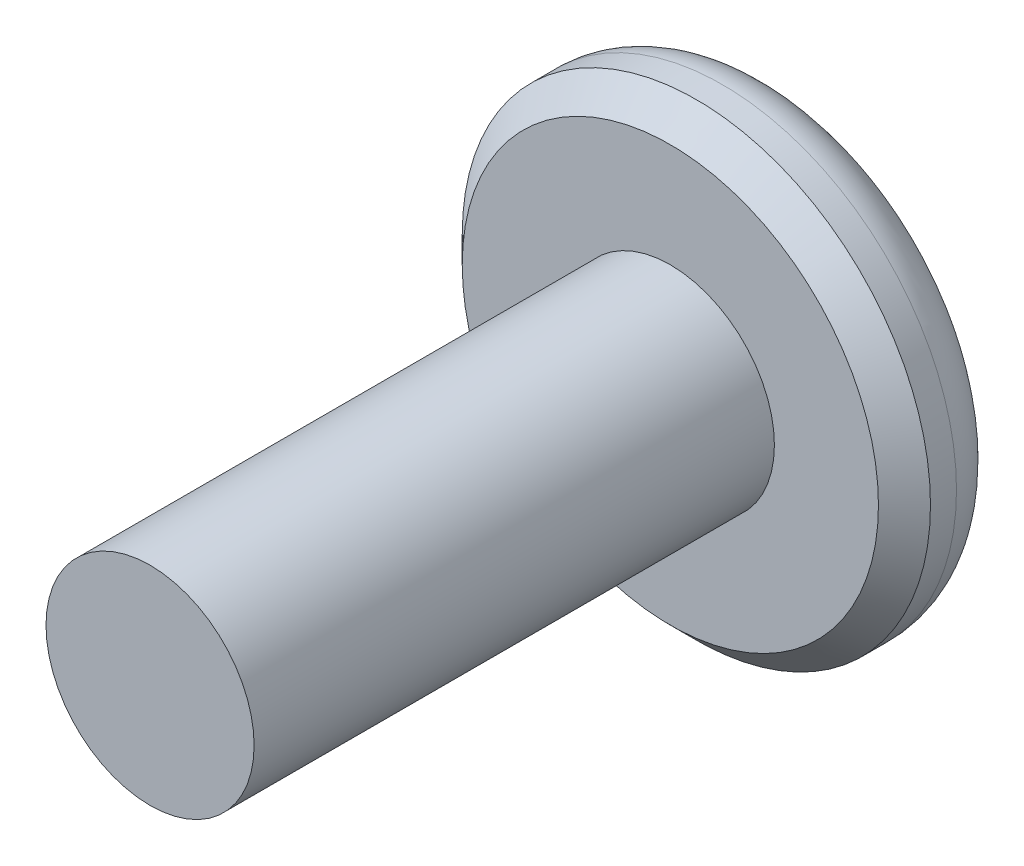
from build123d import *

# Parameters (mm, degrees)
SKETCH_1_R          = 4.5
EXTRUDE_1_DEPTH     = 2
SKETCH_2_R          = 2
EXTRUDE_2_DEPTH     = 10
FILLET_1_R          = 1
CHAMFER_1_SIZE      = 0.5
CUT_EXTRUDE_1_DEPTH = 1


with BuildPart() as part:
    # 草图1 → 凸台-拉伸1 (new body)
    with BuildSketch(Plane.XY):
        Circle(SKETCH_1_R)
    extrude(amount=EXTRUDE_1_DEPTH)

    # 草图2 → 凸台-拉伸2 (add)
    with BuildSketch(Plane.XY.offset(2)):
        Circle(SKETCH_2_R)
    extrude(amount=EXTRUDE_2_DEPTH)

    # 圆角1
    fillet_1_edges = [part.edges().sort_by_distance(p)[0] for p in [
        (-4.5, 0, 0),
    ]]
    fillet(fillet_1_edges, radius=FILLET_1_R)

    # 倒角1
    chamfer_1_edges = [part.edges().sort_by_distance(p)[0] for p in [
        (-4.5, 0, 2),
    ]]
    chamfer(chamfer_1_edges, length=CHAMFER_1_SIZE)

    # 草图3 → 切除-拉伸1 (cut)
    with BuildSketch(Plane(origin=(0, 0, 0), x_dir=(-1, 0, 0), z_dir=(0, 0, -1))):
        Polygon((-0.866025404, 1.5), (-1.732050808, 0), (-0.866025404, -1.5), (0.866025404, -1.5), (1.732050808, 0), (0.866025404, 1.5), align=None)
    extrude(amount=-CUT_EXTRUDE_1_DEPTH, mode=Mode.SUBTRACT)


solid = part.part
